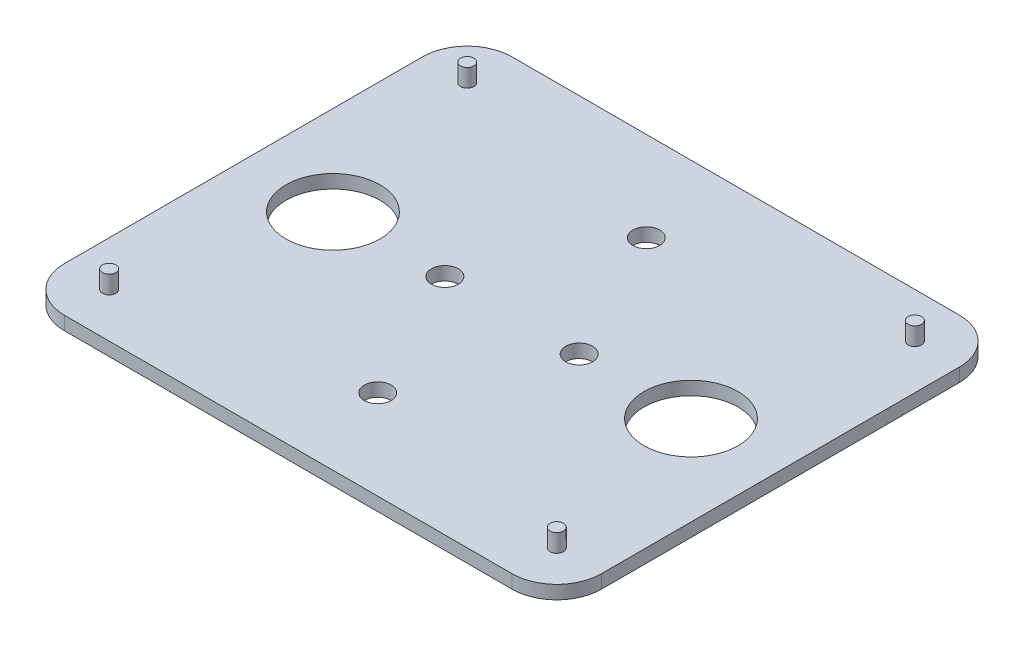
from build123d import *

# Parameters (mm, degrees)
ESQUISSE1_W             = 120
ESQUISSE1_H             = 100
BOSS_EXTRU_1_DEPTH      = 3
CONG_1_R                = 10
ESQUISSE2_R             = 1.5
BOSS_EXTRU_2_DEPTH      = 4
ESQUISSE3_R             = 10.5
ESQUISSE3_R_2           = 3
ENL_V_MAT_EXTRU_1_DEPTH = 4


with BuildPart() as part:
    # Esquisse1 → Boss.-Extru.1 (new body)
    with BuildSketch(Plane(origin=(0, 0, 0), x_dir=(1, 0, 0), z_dir=(0, 1, 0))):
        with Locations((-60, 50)):
            Rectangle(ESQUISSE1_W, ESQUISSE1_H)
    extrude(amount=BOSS_EXTRU_1_DEPTH)

    # Congé1
    cong_1_edges = [part.edges().sort_by_distance(p)[0] for p in [
        (0, 1.5, 0),
        (-120, 1.5, 0),
        (-120, 1.5, -100),
        (0, 1.5, -100),
    ]]
    fillet(cong_1_edges, radius=CONG_1_R)

    # Esquisse2 → Boss.-Extru.2 (add)
    with BuildSketch(Plane(origin=(0, 3, 0), x_dir=(1, 0, 0), z_dir=(0, 1, 0))):
        with Locations((-110, 90)):
            Circle(ESQUISSE2_R)
        with Locations((-10, 90)):
            Circle(ESQUISSE2_R)
        with Locations((-10, 10)):
            Circle(ESQUISSE2_R)
        with Locations((-110, 10)):
            Circle(ESQUISSE2_R)
    extrude(amount=BOSS_EXTRU_2_DEPTH)

    # Esquisse3 → Enlèv. mat.-Extru.1 (cut, through all)
    with BuildSketch(Plane(origin=(0, 3, 0), x_dir=(1, 0, 0), z_dir=(0, 1, 0))):
        with Locations((-100, 50)):
            Circle(ESQUISSE3_R)
        with Locations((-20, 50)):
            Circle(ESQUISSE3_R)
        with Locations((-75, 50)):
            Circle(ESQUISSE3_R_2)
        with Locations((-45, 50)):
            Circle(ESQUISSE3_R_2)
        with Locations((-60, 80)):
            Circle(ESQUISSE3_R_2)
        with Locations((-60, 20)):
            Circle(ESQUISSE3_R_2)
    extrude(amount=-ENL_V_MAT_EXTRU_1_DEPTH, mode=Mode.SUBTRACT)


solid = part.part
